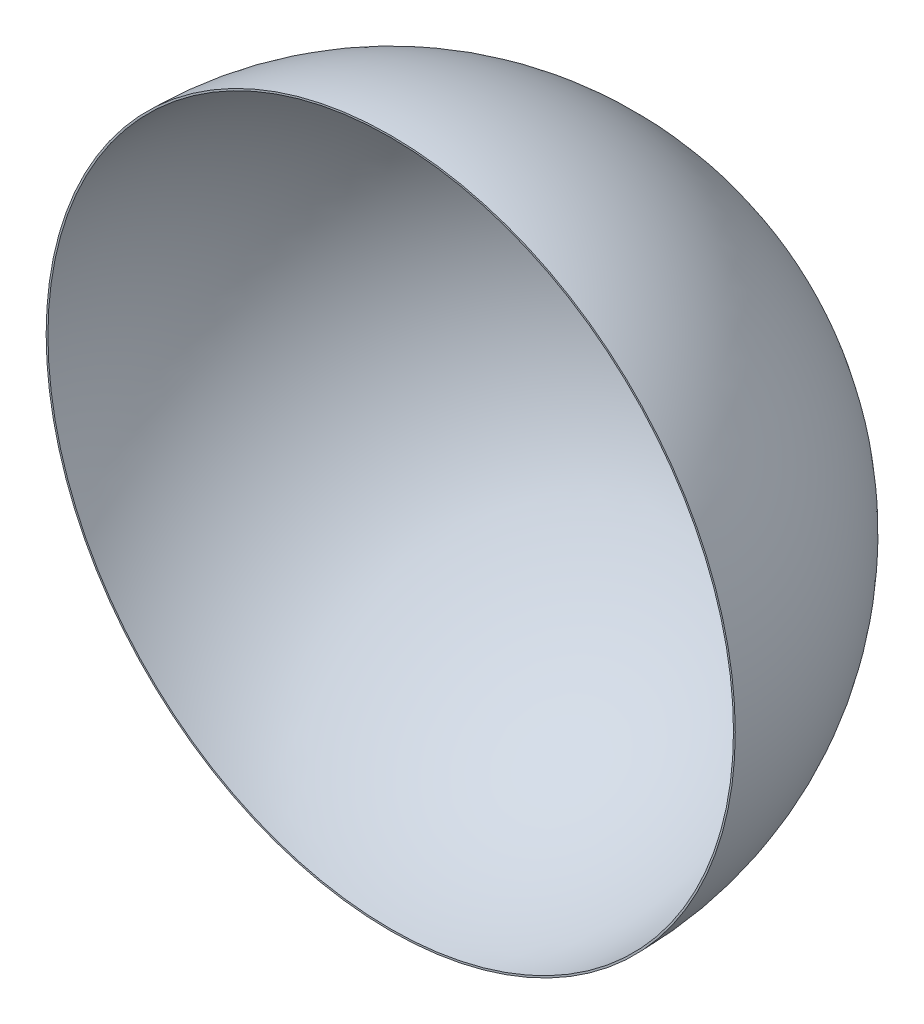
from build123d import *


with BuildPart() as part:
    # Sketch1 → Revolve2 (revolve)
    with BuildSketch(Plane(origin=(0, 0, 0), x_dir=(1, 0, 0), z_dir=(0, 1, 0))):
        with BuildLine():
            Line((0, 0), (0, 25.4))
            ThreePointArc((0, 25.4), (3466.378862733, -1410.421137267), (4902.2, -4876.8))
            Line((4902.2, -4876.8), (4876.8, -4876.8))
            ThreePointArc((4876.8, -4876.8), (3448.418350491, -1428.381649509), (0, 0))
        make_face()
    revolve(axis=Axis((0, 0, 0), (0, 0, 1)))


solid = part.part
